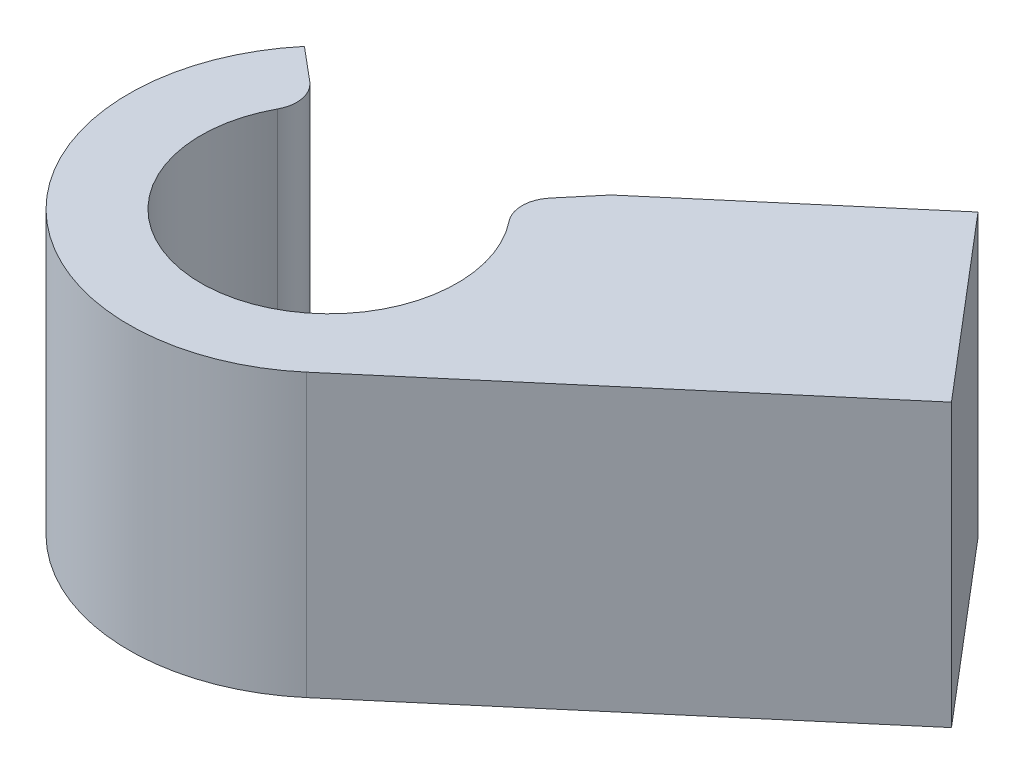
from build123d import *

# Parameters (mm, degrees)
SKETCH1_R           = 12.5
BOSS_EXTRUDE1_DEPTH = 17.6
SKETCH2_R           = 5.5
CUT_EXTRUDE1_DEPTH  = 50.8
SKETCH3_R           = 8
CUT_EXTRUDE3_DEPTH  = 15.6
CUT_EXTRUDE4_DEPTH  = 18.6
BOSS_EXTRUDE2_DEPTH = 17.6
FILLET1_R           = 2


with BuildPart() as part:
    # Sketch1 → Boss-Extrude1 (new body)
    with BuildSketch(Plane(origin=(0, 0, 0), x_dir=(1, 0, 0), z_dir=(0, 1, 0))):
        Circle(SKETCH1_R)
    extrude(amount=BOSS_EXTRUDE1_DEPTH)

    # Sketch2 → Cut-Extrude1 (cut)
    with BuildSketch(Plane(origin=(0, 17.6, 0), x_dir=(1, 0, 0), z_dir=(0, 1, 0))):
        Circle(SKETCH2_R)
    extrude(amount=-CUT_EXTRUDE1_DEPTH, mode=Mode.SUBTRACT)

    # Sketch3 → Cut-Extrude3 (cut)
    with BuildSketch(Plane(origin=(0, 17.6, 0), x_dir=(1, 0, 0), z_dir=(0, 1, 0))):
        Circle(SKETCH3_R)
    extrude(amount=-CUT_EXTRUDE3_DEPTH, mode=Mode.SUBTRACT)

    # Sketch4 → Cut-Extrude4 (cut, through all)
    with BuildSketch(Plane(origin=(0, 17.6, 0), x_dir=(1, 0, 0), z_dir=(0, 1, 0))):
        with BuildLine():
            ThreePointArc((-6.128355545, 5.142300877), (-0.697245942, 7.969557585), (5.142300877, 6.128355545))
            Line((5.142300877, 6.128355545), (8.034845121, 9.575555539))
            ThreePointArc((8.034845121, 9.575555539), (-1.089446784, 12.452433726), (-9.575555539, 8.034845121))
            Line((-9.575555539, 8.034845121), (-6.128355545, 5.142300877))
        make_face()
    extrude(amount=-CUT_EXTRUDE4_DEPTH, mode=Mode.SUBTRACT)

    # Sketch5 → Boss-Extrude2 (add, through all)
    with BuildSketch(Plane(origin=(0, 17.6, 0), x_dir=(1, 0, 0), z_dir=(0, 1, 0))):
        with BuildLine():
            Line((29.863521208, 8.997262141), (20.411315049, 20.106230978))
            Line((20.411315049, 20.106230978), (8.034845121, 9.575555539))
            ThreePointArc((8.034845121, 9.575555539), (12.499926406, 0.042893271), (8.100371818, -9.520187835))
            Line((8.100371818, -9.520187835), (29.863521208, 8.997262141))
        make_face()
    extrude(amount=-BOSS_EXTRUDE2_DEPTH)

    # Fillet1
    fillet1_edges = [part.edges().sort_by_distance(p)[0] for p in [
        (5.142300877, 9.8, -6.128355545),
        (-6.128355545, 9.8, -5.142300877),
    ]]
    fillet(fillet1_edges, radius=FILLET1_R)


solid = part.part
